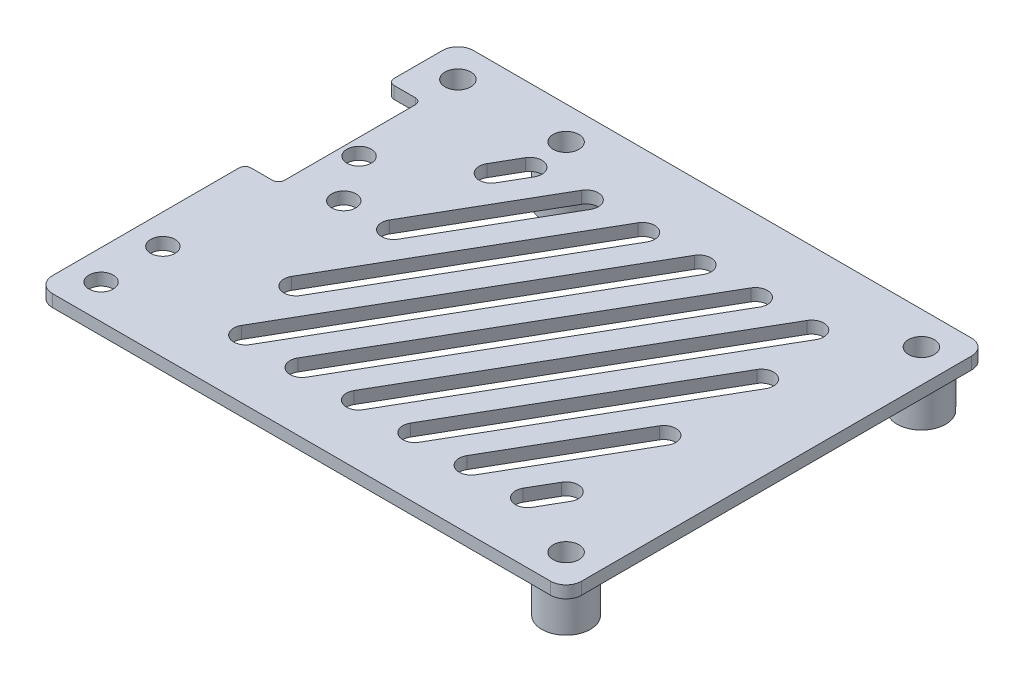
from build123d import *

# Parameters (mm, degrees)
SKETCH1_W           = 87
SKETCH1_H           = 69.22
SKETCH1_R           = 2.125
BOSS_EXTRUDE1_DEPTH = 2
SKETCH2_R           = 4
SKETCH2_R_2         = 2.125
BOSS_EXTRUDE2_DEPTH = 7
SKETCH3_W           = 5.5
SKETCH3_H           = 23.5
CUT_EXTRUDE1_DEPTH  = 7
SKETCH4_R           = 2
CUT_EXTRUDE2_DEPTH  = 7
CUT_EXTRUDE3_DEPTH  = 5
SKETCH6_R           = 2
CUT_EXTRUDE4_DEPTH  = 10
FILLET1_R           = 1
FILLET2_R           = 2.54


with BuildPart() as part:
    # Sketch1 → Boss-Extrude1 (new body)
    with BuildSketch(Plane(origin=(0, 0, 0), x_dir=(1, 0, 0), z_dir=(0, 1, 0))):
        Rectangle(SKETCH1_W, SKETCH1_H)
        with Locations((-38.1, 29.21)):
            Circle(SKETCH1_R, mode=Mode.SUBTRACT)
        with Locations((38.1, 29.21)):
            Circle(SKETCH1_R, mode=Mode.SUBTRACT)
        with Locations((-20.32, 29.21)):
            Circle(SKETCH1_R, mode=Mode.SUBTRACT)
        with Locations((38.1, -29.21)):
            Circle(SKETCH1_R, mode=Mode.SUBTRACT)
    extrude(amount=BOSS_EXTRUDE1_DEPTH)

    # Sketch2 → Boss-Extrude2 (add)
    with BuildSketch(Plane.XZ):
        with Locations((38.1, -29.21)):
            Circle(SKETCH2_R)
        with Locations((38.1, -29.21)):
            Circle(SKETCH2_R_2, mode=Mode.SUBTRACT)
        with Locations((-20.32, -29.21)):
            Circle(SKETCH2_R)
        with Locations((-20.32, -29.21)):
            Circle(SKETCH2_R_2, mode=Mode.SUBTRACT)
        with Locations((-38.1, -29.21)):
            Circle(SKETCH2_R)
        with Locations((-38.1, -29.21)):
            Circle(SKETCH2_R_2, mode=Mode.SUBTRACT)
        with Locations((38.1, 29.21)):
            Circle(SKETCH2_R)
        with Locations((38.1, 29.21)):
            Circle(SKETCH2_R_2, mode=Mode.SUBTRACT)
    extrude(amount=BOSS_EXTRUDE2_DEPTH)

    # Sketch3 → Cut-Extrude1 (cut)
    with BuildSketch(Plane(origin=(0, 2, 0), x_dir=(1, 0, 0), z_dir=(0, 1, 0))):
        with Locations((-40.75, 11.36)):
            Rectangle(SKETCH3_W, SKETCH3_H)
    extrude(amount=-CUT_EXTRUDE1_DEPTH, mode=Mode.SUBTRACT)

    # Sketch4 → Cut-Extrude2 (cut)
    with BuildSketch(Plane(origin=(0, 2, 0), x_dir=(1, 0, 0), z_dir=(0, 1, 0))):
        with Locations((-38.59, -28.97)):
            Circle(SKETCH4_R)
        with Locations((-38.59, -18.81)):
            Circle(SKETCH4_R)
        with Locations((-35.3, 10.16)):
            Circle(SKETCH4_R)
    extrude(amount=-CUT_EXTRUDE2_DEPTH, mode=Mode.SUBTRACT)

    # Sketch5 → Cut-Extrude3 (cut)
    with BuildSketch(Plane(origin=(0, 2, 0), x_dir=(1, 0, 0), z_dir=(0, 1, 0))):
        with BuildLine():
            Line((-23.732050808, 19.61), (-21.422649731, 23.61))
            ThreePointArc((-21.422649731, 23.61), (-18.690598923, 24.342050808), (-17.958548116, 21.61))
            Line((-17.958548116, 21.61), (-20.267949192, 17.61))
            ThreePointArc((-20.267949192, 17.61), (-23, 16.877949192), (-23.732050808, 19.61))
        make_face()
        with BuildLine():
            Line((-23.732050808, 3.557422926), (-12.154690036, 23.61))
            ThreePointArc((-12.154690036, 23.61), (-9.422639229, 24.342050808), (-8.690588421, 21.61))
            Line((-8.690588421, 21.61), (-20.267949192, 1.557422926))
            ThreePointArc((-20.267949192, 1.557422926), (-23, 0.825372119), (-23.732050808, 3.557422926))
        make_face()
        with BuildLine():
            Line((-23.732050808, -12.495154147), (-2.886730341, 23.61))
            ThreePointArc((-2.886730341, 23.61), (-0.154679534, 24.342050808), (0.577371274, 21.61))
            Line((0.577371274, 21.61), (-20.267949192, -14.495154147))
            ThreePointArc((-20.267949192, -14.495154147), (-23, -15.227204955), (-23.732050808, -12.495154147))
        make_face()
        with BuildLine():
            Line((9.845330968, 21.61), (-17.417148743, -25.61))
            ThreePointArc((-17.417148743, -25.61), (-20.14919955, -26.342050808), (-20.881250358, -23.61))
            Line((-20.881250358, -23.61), (6.381229353, 23.61))
            ThreePointArc((6.381229353, 23.61), (9.113280161, 24.342050808), (9.845330968, 21.61))
        make_face()
        with BuildLine():
            Line((-11.613290663, -23.61), (15.649189048, 23.61))
            ThreePointArc((15.649189048, 23.61), (18.381239856, 24.342050808), (19.113290663, 21.61))
            Line((19.113290663, 21.61), (-8.149189048, -25.61))
            ThreePointArc((-8.149189048, -25.61), (-10.881239856, -26.342050808), (-11.613290663, -23.61))
        make_face()
        with BuildLine():
            Line((28.381250358, 21.61), (1.118770647, -25.61))
            ThreePointArc((1.118770647, -25.61), (-1.613280161, -26.342050808), (-2.345330968, -23.61))
            Line((-2.345330968, -23.61), (24.917148743, 23.61))
            ThreePointArc((24.917148743, 23.61), (27.64919955, 24.342050808), (28.381250358, 21.61))
        make_face()
        with BuildLine():
            Line((6.922628726, -23.61), (27.767949192, 12.495154147))
            ThreePointArc((27.767949192, 12.495154147), (30.5, 13.227204955), (31.232050808, 10.495154147))
            Line((31.232050808, 10.495154147), (10.386730341, -25.61))
            ThreePointArc((10.386730341, -25.61), (7.654679534, -26.342050808), (6.922628726, -23.61))
        make_face()
        with BuildLine():
            Line((31.232050808, -5.557422926), (19.654690036, -25.61))
            ThreePointArc((19.654690036, -25.61), (16.922639229, -26.342050808), (16.190588421, -23.61))
            Line((16.190588421, -23.61), (27.767949192, -3.557422926))
            ThreePointArc((27.767949192, -3.557422926), (30.5, -2.825372119), (31.232050808, -5.557422926))
        make_face()
        with BuildLine():
            Line((25.458548116, -23.61), (27.767949192, -19.61))
            ThreePointArc((27.767949192, -19.61), (30.5, -18.877949192), (31.232050808, -21.61))
            Line((31.232050808, -21.61), (28.922649731, -25.61))
            ThreePointArc((28.922649731, -25.61), (26.190598923, -26.342050808), (25.458548116, -23.61))
        make_face()
    extrude(amount=-CUT_EXTRUDE3_DEPTH, mode=Mode.SUBTRACT)

    # Sketch6 → Cut-Extrude4 (cut)
    with BuildSketch(Plane(origin=(0, 2, 0), x_dir=(1, 0, 0), z_dir=(0, 1, 0))):
        with Locations((-30.2, 2.54)):
            Circle(SKETCH6_R)
    extrude(amount=-CUT_EXTRUDE4_DEPTH, mode=Mode.SUBTRACT)

    # Fillet1
    fillet1_edges = [part.edges().sort_by_distance(p)[0] for p in [
        (-38, 1, -23.11),
        (-38, 1, 0.39),
        (-43.5, 1, 0.39),
        (-43.5, 1, -23.11),
    ]]
    fillet(fillet1_edges, radius=FILLET1_R)

    # Fillet2
    fillet2_edges = [part.edges().sort_by_distance(p)[0] for p in [
        (-43.5, 1, 34.61),
        (-43.5, 1, -34.61),
        (43.5, 1, -34.61),
        (43.5, 1, 34.61),
    ]]
    fillet(fillet2_edges, radius=FILLET2_R)


solid = part.part
